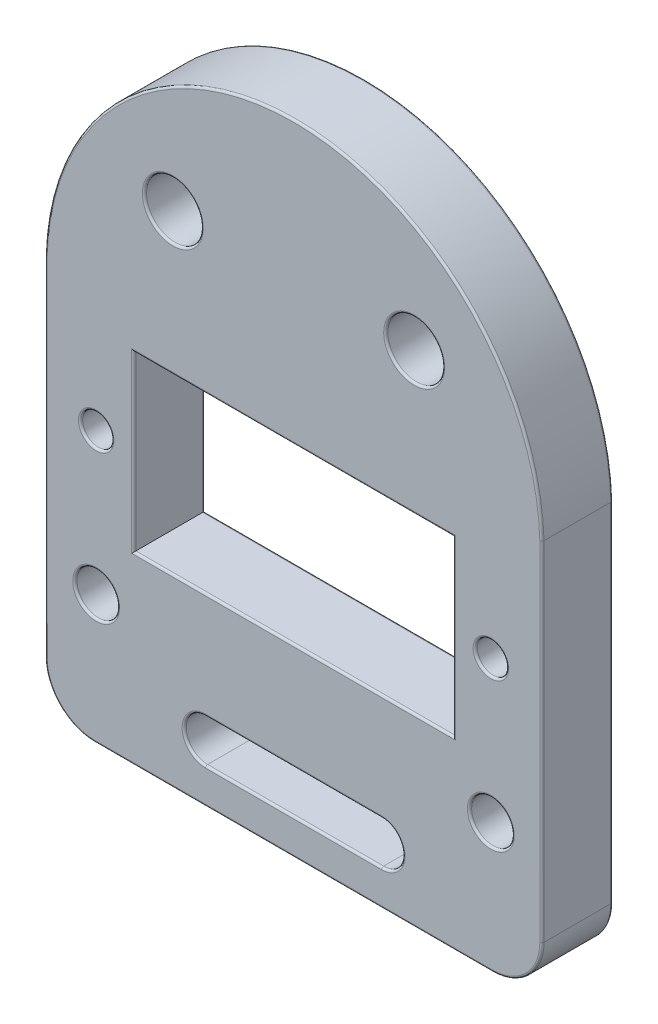
from build123d import *

# Parameters (mm, degrees)
SZKIC1_R                    = 1.1
SZKIC1_R_2                  = 1.5
SZKIC1_R_3                  = 2
SZKIC1_W                    = 22.5
SZKIC1_H                    = 12.2
DODANIE_WYCI_GNI_CIE1_DEPTH = 5
ZAOKR_GLENIE1_R             = 3.5
ZAOKR_GLENIE2_R             = 0.15


with BuildPart() as part:
    # Szkic1 → Dodanie-wyciągnięcie1 (new body)
    with BuildSketch(Plane.XY):
        with BuildLine():
            Line((-17.5, 8.9), (-17.5, -19.1))
            Line((-17.5, -19.1), (17.5, -19.1))
            Line((17.5, -19.1), (17.5, 8.9))
            ThreePointArc((17.5, 8.9), (0, 25.9), (-17.5, 8.9))
        make_face()
        with Locations((-13.9, 0)):
            Circle(SZKIC1_R, mode=Mode.SUBTRACT)
        with Locations((-13.9, -10)):
            Circle(SZKIC1_R_2, mode=Mode.SUBTRACT)
        with Locations((-8.5, 16.1)):
            Circle(SZKIC1_R_3, mode=Mode.SUBTRACT)
        with Locations((13.9, -10)):
            Circle(SZKIC1_R_2, mode=Mode.SUBTRACT)
        with Locations((13.9, 0)):
            Circle(SZKIC1_R, mode=Mode.SUBTRACT)
        with Locations((8.5, 16.1)):
            Circle(SZKIC1_R_3, mode=Mode.SUBTRACT)
        Rectangle(SZKIC1_W, SZKIC1_H, mode=Mode.SUBTRACT)
        with BuildLine():
            Line((-6.2, -13.6), (6.2, -13.6))
            ThreePointArc((6.2, -13.6), (7.7, -15.1), (6.2, -16.6))
            Line((6.2, -16.6), (-6.2, -16.6))
            ThreePointArc((-6.2, -16.6), (-7.7, -15.1), (-6.2, -13.6))
        make_face(mode=Mode.SUBTRACT)
    extrude(amount=DODANIE_WYCI_GNI_CIE1_DEPTH)

    # Zaokrąglenie1
    zaokr_glenie1_edges = [part.edges().sort_by_distance(p)[0] for p in [
        (17.5, -19.1, 2.5),
        (-17.5, -19.1, 2.5),
    ]]
    fillet(zaokr_glenie1_edges, radius=ZAOKR_GLENIE1_R)

    # Zaokrąglenie2
    zaokr_glenie2_edges = [part.edges().sort_by_distance(p)[0] for p in [
        (11.25, 0, 0),
        (0, 6.1, 0),
        (-11.25, 0, 0),
        (0, -6.1, 0),
        (11.25, 0, 5),
        (0, 6.1, 5),
        (-11.25, 0, 5),
        (0, -6.1, 5),
        (-15, 0, 0),
        (-15, 0, 5),
        (-15.4, -10, 0),
        (-15.4, -10, 5),
        (-7.7, -15.1, 0),
        (0, -16.6, 0),
        (7.7, -15.1, 0),
        (0, -13.6, 0),
        (-7.7, -15.1, 5),
        (0, -16.6, 5),
        (7.7, -15.1, 5),
        (0, -13.6, 5),
        (0, 25.9, 5),
        (-10.5, 16.1, 0),
        (-10.5, 16.1, 5),
        (12.4, -10, 0),
        (12.4, -10, 5),
        (-17.5, -3.35, 0),
        (12.8, 0, 0),
        (12.8, 0, 5),
        (0, 25.9, 0),
        (6.5, 16.1, 0),
        (6.5, 16.1, 5),
        (0, -19.1, 0),
        (0, -19.1, 5),
        (17.5, -3.35, 0),
        (16.474873734, -18.074873734, 0),
        (-16.474873734, -18.074873734, 0),
        (-17.5, -3.35, 5),
        (17.5, -3.35, 5),
        (16.474873734, -18.074873734, 5),
        (-16.474873734, -18.074873734, 5),
    ]]
    fillet(zaokr_glenie2_edges, radius=ZAOKR_GLENIE2_R)


solid = part.part
